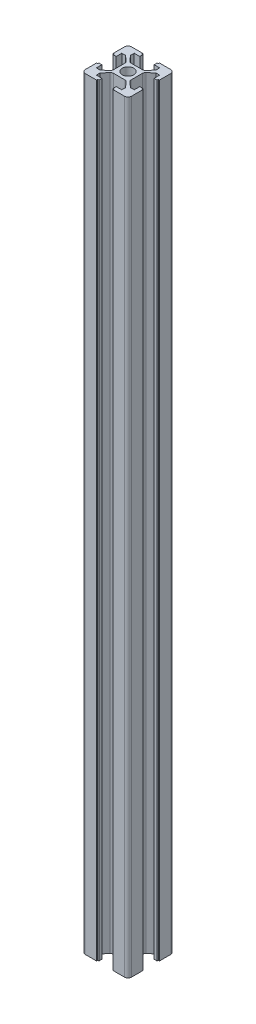
from build123d import *

# Parameters (mm, degrees)
SKETCH1_R           = 2.5
BOSS_EXTRUDE1_DEPTH = 330


with BuildPart() as part:
    # Sketch1 → Boss-Extrude1 (new body)
    with BuildSketch(Plane(origin=(0, 0, 0), x_dir=(1, 0, 0), z_dir=(0, 1, 0))):
        with BuildLine():
            ThreePointArc((-10, -8.5), (-9.560660172, -9.560660172), (-8.5, -10))
            Line((-8.5, -10), (-3.6, -10))
            Line((-3.6, -10), (-3.6, -9.5))
            Line((-3.6, -9.5), (-3.1, -9.5))
            Line((-3.1, -9.5), (-3.1, -8.2))
            Line((-3.1, -8.2), (-5.5, -8.2))
            Line((-5.5, -8.2), (-5.5, -6.6))
            Line((-5.5, -6.6), (-3.54898252, -4.32381294))
            ThreePointArc((-3.54898252, -4.32381294), (-3.036882831, -3.937230652), (-2.410097616, -3.8))
            Line((-2.410097616, -3.8), (2.410097616, -3.8))
            ThreePointArc((2.410097616, -3.8), (3.036882831, -3.937230652), (3.54898252, -4.32381294))
            Line((3.54898252, -4.32381294), (5.5, -6.6))
            Line((5.5, -6.6), (5.5, -8.2))
            Line((5.5, -8.2), (3.1, -8.2))
            Line((3.1, -8.2), (3.1, -9.5))
            Line((3.1, -9.5), (3.6, -9.5))
            Line((3.6, -9.5), (3.6, -10))
            Line((3.6, -10), (8.5, -10))
            ThreePointArc((8.5, -10), (9.560660172, -9.560660172), (10, -8.5))
            Line((10, -8.5), (10, -3.6))
            Line((10, -3.6), (9.5, -3.6))
            Line((9.5, -3.6), (9.5, -3.1))
            Line((9.5, -3.1), (8.2, -3.1))
            Line((8.2, -3.1), (8.2, -5.5))
            Line((8.2, -5.5), (6.6, -5.5))
            Line((6.6, -5.5), (4.32381294, -3.54898252))
            ThreePointArc((4.32381294, -3.54898252), (3.937230652, -3.036882831), (3.8, -2.410097616))
            Line((3.8, -2.410097616), (3.8, 2.410097616))
            ThreePointArc((3.8, 2.410097616), (3.937230652, 3.036882831), (4.32381294, 3.54898252))
            Line((4.32381294, 3.54898252), (6.6, 5.5))
            Line((6.6, 5.5), (8.2, 5.5))
            Line((8.2, 5.5), (8.2, 3.1))
            Line((8.2, 3.1), (9.5, 3.1))
            Line((9.5, 3.1), (9.5, 3.6))
            Line((9.5, 3.6), (10, 3.6))
            Line((10, 3.6), (10, 8.5))
            ThreePointArc((10, 8.5), (9.560660172, 9.560660172), (8.5, 10))
            Line((8.5, 10), (3.6, 10))
            Line((3.6, 10), (3.6, 9.5))
            Line((3.6, 9.5), (3.1, 9.5))
            Line((3.1, 9.5), (3.1, 8.2))
            Line((3.1, 8.2), (5.5, 8.2))
            Line((5.5, 8.2), (5.5, 6.6))
            Line((5.5, 6.6), (3.54898252, 4.32381294))
            ThreePointArc((3.54898252, 4.32381294), (3.036882831, 3.937230652), (2.410097616, 3.8))
            Line((2.410097616, 3.8), (-2.410097616, 3.8))
            ThreePointArc((-2.410097616, 3.8), (-3.036882831, 3.937230652), (-3.54898252, 4.32381294))
            Line((-3.54898252, 4.32381294), (-5.5, 6.6))
            Line((-5.5, 6.6), (-5.5, 8.2))
            Line((-5.5, 8.2), (-3.1, 8.2))
            Line((-3.1, 8.2), (-3.1, 9.5))
            Line((-3.1, 9.5), (-3.6, 9.5))
            Line((-3.6, 9.5), (-3.6, 10))
            Line((-3.6, 10), (-8.5, 10))
            ThreePointArc((-8.5, 10), (-9.560660172, 9.560660172), (-10, 8.5))
            Line((-10, 8.5), (-10, 3.6))
            Line((-10, 3.6), (-9.5, 3.6))
            Line((-9.5, 3.6), (-9.5, 3.1))
            Line((-9.5, 3.1), (-8.2, 3.1))
            Line((-8.2, 3.1), (-8.2, 5.5))
            Line((-8.2, 5.5), (-6.6, 5.5))
            Line((-6.6, 5.5), (-4.32381294, 3.54898252))
            ThreePointArc((-4.32381294, 3.54898252), (-3.937230652, 3.036882831), (-3.8, 2.410097616))
            Line((-3.8, 2.410097616), (-3.8, -2.410097616))
            ThreePointArc((-3.8, -2.410097616), (-3.937230652, -3.036882831), (-4.32381294, -3.54898252))
            Line((-4.32381294, -3.54898252), (-6.6, -5.5))
            Line((-6.6, -5.5), (-8.2, -5.5))
            Line((-8.2, -5.5), (-8.2, -3.1))
            Line((-8.2, -3.1), (-9.5, -3.1))
            Line((-9.5, -3.1), (-9.5, -3.6))
            Line((-9.5, -3.6), (-10, -3.6))
            Line((-10, -3.6), (-10, -8.5))
        make_face()
        Circle(SKETCH1_R, mode=Mode.SUBTRACT)
    extrude(amount=BOSS_EXTRUDE1_DEPTH)


solid = part.part
